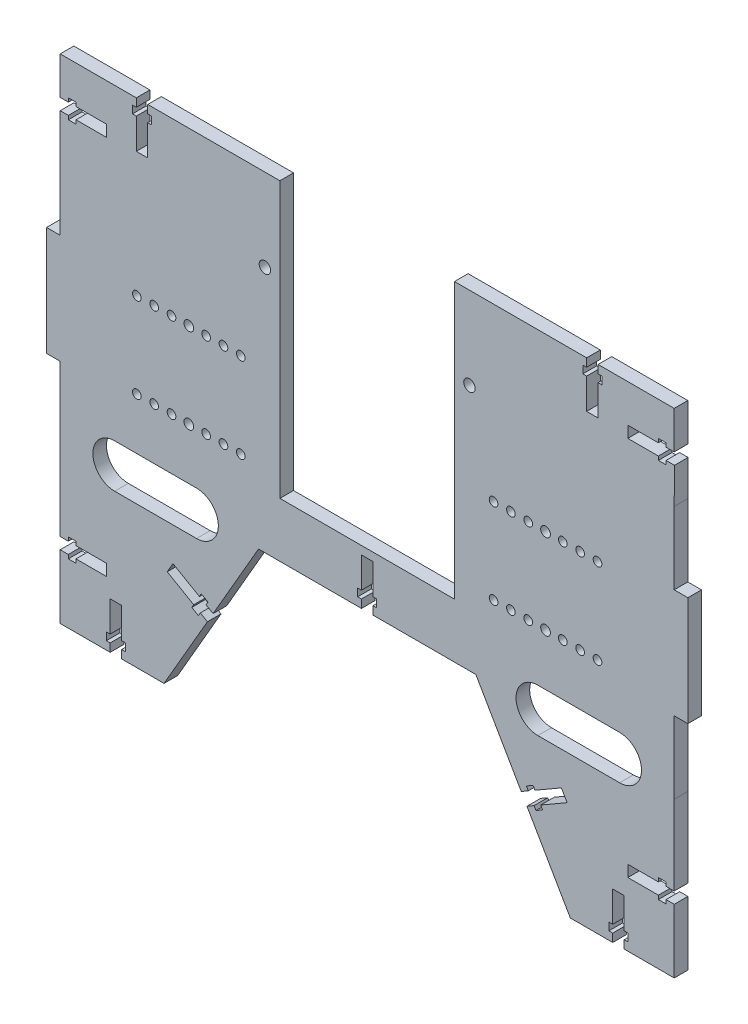
from build123d import *

# Parameters (mm, degrees)
SKETCH1_R           = 2.5
SKETCH1_R_2         = 2
SKETCH1_R_3         = 1.6
SKETCH1_W           = 33
SKETCH1_H           = 80
BOSS_EXTRUDE1_DEPTH = 5
SKETCH2_W           = 33
SKETCH2_H           = 80
BOSS_EXTRUDE2_DEPTH = 5
SKETCH3_W           = 23
SKETCH3_H           = 45
CUT_EXTRUDE3_DEPTH  = 5
SKETCH4_R           = 2.5
SKETCH4_R_2         = 2
SKETCH4_R_3         = 1.6
BOSS_EXTRUDE3_DEPTH = 5
SKETCH5_R           = 1.5875
SKETCH5_R_2         = 1.777507088
CUT_EXTRUDE4_DEPTH  = 5
CUT_EXTRUDE5_DEPTH  = 10
CUT_EXTRUDE9_DEPTH  = 10
CUT_EXTRUDE10_DEPTH = 10
SKETCH14_W          = 5
SKETCH14_H          = 4.2
CUT_EXTRUDE11_DEPTH = 10
SKETCH16_W          = 6.992402248
SKETCH16_H          = 3.319579164
CUT_EXTRUDE13_DEPTH = 5
SKETCH17_W          = 18
SKETCH17_H          = 45
CUT_EXTRUDE14_DEPTH = 5
SKETCH18_W          = 5
SKETCH18_H          = 100.853444487
BOSS_EXTRUDE4_DEPTH = 9
SKETCH19_R          = 2.1
CUT_EXTRUDE15_DEPTH = 5
BOSS_EXTRUDE5_DEPTH = 5
BOSS_EXTRUDE6_DEPTH = 5
CUT_EXTRUDE16_DEPTH = 5
CUT_EXTRUDE17_DEPTH = 5


with BuildPart() as part:
    # Sketch1 → Boss-Extrude1 (new body)
    with BuildSketch(Plane.XY):
        with BuildLine():
            Line((117.028043007, -95.833189988), (117.028043007, -34.826010178))
            Line((117.028043007, -34.826010178), (112.428043007, -34.826010178))
            ThreePointArc((112.428043007, -34.826010178), (108.892509101, -33.361544084), (107.428043007, -29.826010178))
            Line((107.428043007, -29.826010178), (107.428043007, 53.159630202))
            ThreePointArc((107.428043007, 53.159630202), (108.892509101, 56.695164108), (112.428043007, 58.159630202))
            Line((112.428043007, 58.159630202), (117.026703355, 58.159630202))
            Line((117.026703355, 58.159630202), (117.026347368, 74.955032384))
            Line((117.026347368, 74.955032384), (117.009335684, 95.020254499))
            Line((117.009335684, 95.020254499), (36.10896173, 95.020254499))
            ThreePointArc((36.10896173, 95.020254499), (-0.541956993, 85.455032384), (-37.192875715, 95.020254499))
            Line((-37.192875715, 95.020254499), (-118.09324967, 95.020254499))
            Line((-118.09324967, 95.020254499), (-118.110261354, 74.955032384))
            Line((-118.110261354, 74.955032384), (-118.110617341, 58.159630202))
            Line((-118.110617341, 58.159630202), (-113.511956993, 58.159630202))
            ThreePointArc((-113.511956993, 58.159630202), (-109.976423087, 56.695164108), (-108.511956993, 53.159630202))
            Line((-108.511956993, 53.159630202), (-108.511956993, -29.826010178))
            ThreePointArc((-108.511956993, -29.826010178), (-109.976423087, -33.361544084), (-113.511956993, -34.826010178))
            Line((-113.511956993, -34.826010178), (-118.111956993, -34.826010178))
            Line((-118.111956993, -34.826010178), (-118.111956993, -95.833189988))
            Line((-118.111956993, -95.833189988), (-72.133390372, -95.833189988))
            Line((-72.133390372, -95.833189988), (-37.492374221, -35.833189988))
            Line((-37.492374221, -35.833189988), (36.408460235, -35.833189988))
            Line((36.408460235, -35.833189988), (71.049476387, -95.833189988))
            Line((71.049476387, -95.833189988), (117.028043007, -95.833189988))
        make_face()
        with Locations((-93.741956993, 37.166810012)):
            Circle(SKETCH1_R, mode=Mode.SUBTRACT)
        with Locations((-93.741956993, -13.833189988)):
            Circle(SKETCH1_R, mode=Mode.SUBTRACT)
        with Locations((92.658043007, -13.833189988)):
            Circle(SKETCH1_R, mode=Mode.SUBTRACT)
        with Locations((92.658043007, 37.166810012)):
            Circle(SKETCH1_R, mode=Mode.SUBTRACT)
        with Locations((35.458043007, 29.166810012)):
            Circle(SKETCH1_R_2, mode=Mode.SUBTRACT)
        with Locations((35.458043007, -5.833189988)):
            Circle(SKETCH1_R_2, mode=Mode.SUBTRACT)
        with Locations((4.458043007, -5.833189988)):
            Circle(SKETCH1_R_2, mode=Mode.SUBTRACT)
        with Locations((-5.541956993, -5.833189988)):
            Circle(SKETCH1_R_2, mode=Mode.SUBTRACT)
        with Locations((-36.541956993, -5.833189988)):
            Circle(SKETCH1_R_2, mode=Mode.SUBTRACT)
        with Locations((-36.541956993, 29.166810012)):
            Circle(SKETCH1_R_2, mode=Mode.SUBTRACT)
        with Locations((4.458043007, 29.166810012)):
            Circle(SKETCH1_R_2, mode=Mode.SUBTRACT)
        with Locations((-5.541956993, 29.166810012)):
            Circle(SKETCH1_R_2, mode=Mode.SUBTRACT)
        with Locations((25.922509101, 60.990566289)):
            Circle(SKETCH1_R_3, mode=Mode.SUBTRACT)
        with Locations((25.922509101, 81.919498478)):
            Circle(SKETCH1_R_3, mode=Mode.SUBTRACT)
        with Locations((-27.006423087, 81.919498478)):
            Circle(SKETCH1_R_3, mode=Mode.SUBTRACT)
        with Locations((-27.006423087, 60.990566289)):
            Circle(SKETCH1_R_3, mode=Mode.SUBTRACT)
        with Locations((55.958043007, 11.666810012)):
            Rectangle(SKETCH1_W, SKETCH1_H, mode=Mode.SUBTRACT)
        with Locations((-57.041956993, 11.666810012)):
            Rectangle(SKETCH1_W, SKETCH1_H, mode=Mode.SUBTRACT)
    extrude(amount=BOSS_EXTRUDE1_DEPTH)

    # Sketch2 → Boss-Extrude2 (add)
    with BuildSketch(Plane.XY.offset(5)):
        with Locations((55.958043007, 11.666810012)):
            Rectangle(SKETCH2_W, SKETCH2_H)
        with Locations((-57.041956993, 11.666810012)):
            Rectangle(SKETCH2_W, SKETCH2_H)
    extrude(amount=-BOSS_EXTRUDE2_DEPTH)

    # Sketch3 → Cut-Extrude3 (cut)
    with BuildSketch(Plane.XY.offset(5)):
        with Locations((19.958043007, 10.9416372)):
            Rectangle(SKETCH3_W, SKETCH3_H)
        with Locations((-21.041956993, 10.9416372)):
            Rectangle(SKETCH3_W, SKETCH3_H)
    extrude(amount=-CUT_EXTRUDE3_DEPTH, mode=Mode.SUBTRACT)

    # Sketch4 → Boss-Extrude3 (add)
    with BuildSketch(Plane.XY.offset(5)):
        with Locations((92.658043007, -13.833189988)):
            Circle(SKETCH4_R)
        with Locations((92.658043007, 37.166810012)):
            Circle(SKETCH4_R)
        with Locations((35.458043007, -5.833189988)):
            Circle(SKETCH4_R_2)
        with Locations((35.458043007, 29.166810012)):
            Circle(SKETCH4_R_2)
        with Locations((4.458043007, -5.833189988)):
            Circle(SKETCH4_R_2)
        with Locations((4.458043007, 29.166810012)):
            Circle(SKETCH4_R_2)
        with Locations((-5.541956993, -5.833189988)):
            Circle(SKETCH4_R_2)
        with Locations((-5.541956993, 29.166810012)):
            Circle(SKETCH4_R_2)
        with Locations((-36.541956993, -5.833189988)):
            Circle(SKETCH4_R_2)
        with Locations((-36.541956993, 29.166810012)):
            Circle(SKETCH4_R_2)
        with Locations((-93.741956993, -13.833189988)):
            Circle(SKETCH4_R)
        with Locations((-93.741956993, 37.166810012)):
            Circle(SKETCH4_R)
        with Locations((25.922509101, 60.990566289)):
            Circle(SKETCH4_R_3)
        with Locations((25.922509101, 81.919498478)):
            Circle(SKETCH4_R_3)
        with Locations((-27.006423087, 81.919498478)):
            Circle(SKETCH4_R_3)
        with Locations((-27.006423087, 60.990566289)):
            Circle(SKETCH4_R_3)
    extrude(amount=-BOSS_EXTRUDE3_DEPTH)

    # Sketch5 → Cut-Extrude4 (cut)
    with BuildSketch(Plane.XY.offset(5)):
        with Locations((-84.979456993, 26.5626372)):
            Circle(SKETCH5_R)
        with Locations((-78.629456993, 26.5626372)):
            Circle(SKETCH5_R)
        with Locations((-72.279456993, 26.5626372)):
            Circle(SKETCH5_R)
        with Locations((-65.929456993, 26.5626372)):
            Circle(SKETCH5_R_2)
        with Locations((-59.579456993, 26.5626372)):
            Circle(SKETCH5_R)
        with Locations((-53.229456993, 26.5626372)):
            Circle(SKETCH5_R)
        with Locations((-46.879456993, 26.5626372)):
            Circle(SKETCH5_R)
        with Locations((-46.879456993, -4.682347762)):
            Circle(SKETCH5_R)
        with Locations((-53.229456993, -4.682347762)):
            Circle(SKETCH5_R)
        with Locations((-59.579456993, -4.682347762)):
            Circle(SKETCH5_R)
        with Locations((-65.929456993, -4.682347762)):
            Circle(SKETCH5_R_2)
        with Locations((-72.279456993, -4.682347762)):
            Circle(SKETCH5_R)
        with Locations((-78.629456993, -4.682347762)):
            Circle(SKETCH5_R)
        with Locations((-84.979456993, -4.682347762)):
            Circle(SKETCH5_R)
        with Locations((83.895543007, -4.682347762)):
            Circle(SKETCH5_R)
        with Locations((77.545543007, -4.682347762)):
            Circle(SKETCH5_R)
        with Locations((71.195543007, -4.682347762)):
            Circle(SKETCH5_R)
        with Locations((64.845543007, -4.682347762)):
            Circle(SKETCH5_R_2)
        with Locations((58.495543007, -4.682347762)):
            Circle(SKETCH5_R)
        with Locations((52.145543007, -4.682347762)):
            Circle(SKETCH5_R)
        with Locations((45.795543007, -4.682347762)):
            Circle(SKETCH5_R)
        with Locations((45.795543007, 26.5626372)):
            Circle(SKETCH5_R)
        with Locations((52.145543007, 26.5626372)):
            Circle(SKETCH5_R)
        with Locations((58.495543007, 26.5626372)):
            Circle(SKETCH5_R)
        with Locations((64.845543007, 26.5626372)):
            Circle(SKETCH5_R_2)
        with Locations((71.195543007, 26.5626372)):
            Circle(SKETCH5_R)
        with Locations((77.545543007, 26.5626372)):
            Circle(SKETCH5_R)
        with Locations((83.895543007, 26.5626372)):
            Circle(SKETCH5_R)
    extrude(amount=-CUT_EXTRUDE4_DEPTH, mode=Mode.SUBTRACT)

    # Sketch7 → Cut-Extrude5 (cut)
    with BuildSketch(Plane.XY.offset(5)):
        Polygon((-113.092855481, 89.295081687), (-113.092875715, 75.465081684), (-113.511956993, 58.159630202), (-118.110617341, 58.159630202), (-118.110261354, 74.955032384), (-118.09324967, 95.020254499), (-37.192875715, 95.020254499), (-37.192875715, 89.295081687), align=None)
        Polygon((36.10896173, 89.295081687), (112.008860559, 89.295081687), (112.00896173, 75.465081684), (117.026703355, 58.159630202), (117.026347368, 74.955032384), (117.009335684, 95.020254499), (36.10896173, 95.020254499), align=None)
        Polygon((112.028043007, -35.5483628), (112.028043007, -91.5583628), (73.936227733, -91.5583628), (73.236587254, -90.346549944), (58.037587254, -64.02110972), (39.295211581, -31.5583628), (-2.641539765, -31.5583628), (-37.491539765, -31.5583628), (-40.379125567, -31.5583628), (-59.12150124, -64.02110972), (-74.32050124, -90.346549944), (-75.020141718, -91.5583628), (-113.111956993, -91.5583628), (-113.111956993, -35.5483628), (-118.111956993, -34.826010178), (-118.111956993, -95.833189988), (-72.133390372, -95.833189988), (-37.492374221, -35.833189988), (36.408460235, -35.833189988), (71.049476387, -95.833189988), (117.028043007, -95.833189988), (117.028043007, -34.826010178), align=None)
    extrude(amount=-CUT_EXTRUDE5_DEPTH, mode=Mode.SUBTRACT)

    # Sketch9 → Cut-Extrude9 (cut)
    with BuildSketch(Plane.XY.offset(5)):
        with BuildLine():
            Line((-107.292875715, 69.865081684), (-107.292875715, 71.265081684))
            Line((-107.292875715, 71.265081684), (-96.092875715, 71.265081684))
            Line((-96.092875715, 71.265081684), (-96.092875715, 75.465081684))
            Line((-96.092875715, 75.465081684), (-107.292875715, 75.465081684))
            Line((-107.292875715, 75.465081684), (-107.292875715, 76.865081684))
            Line((-107.292875715, 76.865081684), (-110.092875715, 76.865081684))
            Line((-110.092875715, 76.865081684), (-110.092875715, 75.465081684))
            Line((-110.092875715, 75.465081684), (-113.092875715, 75.465081684))
            Line((-113.092875715, 75.465081684), (-113.143730828, 73.365081684))
            Line((-113.143730828, 73.365081684), (-113.511956993, 58.159630202))
            ThreePointArc((-113.511956993, 58.159630202), (-113.302231779, 58.155229799), (-113.092875715, 58.142036336))
            Line((-113.092875715, 58.142036336), (-113.092875715, 71.265081684))
            Line((-113.092875715, 71.265081684), (-110.092875715, 71.265081684))
            Line((-110.092875715, 71.265081684), (-110.092875715, 69.865081684))
            Line((-110.092875715, 69.865081684), (-107.292875715, 69.865081684))
        make_face()
        Polygon((-75.542875715, 89.295081687), (-79.742875715, 89.295081687), (-79.742875715, 86.295081684), (-81.142875715, 86.295081684), (-81.142875715, 83.495081684), (-79.742875715, 83.495081684), (-79.742875715, 72.295081687), (-75.542875715, 72.295081687), (-75.542875715, 83.495081684), (-74.142875715, 83.495081684), (-74.142875715, 86.295081684), (-75.542875715, 86.295081684), align=None)
        Polygon((-94.766956993, -91.5583628), (-90.566956993, -91.5583628), (-90.566956993, -88.558362803), (-89.166956993, -88.558362803), (-89.166956993, -85.758362803), (-90.566956993, -85.758362803), (-90.566956993, -74.5583628), (-94.766956993, -74.5583628), (-94.766956993, -85.758362803), (-96.166956993, -85.758362803), (-96.166956993, -88.558362803), (-94.766956993, -88.558362803), align=None)
        Polygon((-113.111956993, -63.9533628), (-113.111956993, -68.1533628), (-110.111956993, -68.1533628), (-110.111956993, -69.5533628), (-107.311956993, -69.5533628), (-107.311956993, -68.1533628), (-96.111956993, -68.1533628), (-96.111956993, -63.9533628), (-107.311956993, -63.9533628), (-107.311956993, -62.5533628), (-110.111956993, -62.5533628), (-110.111956993, -63.9533628), align=None)
        Polygon((-59.121501241, -64.021109722), (-57.021501241, -60.383803026), (-59.619577452, -58.883803026), (-58.919577452, -57.671367461), (-61.344448583, -56.271367461), (-62.044448583, -57.483803026), (-71.743933104, -51.883803027), (-73.843933104, -55.521109723), (-64.144448583, -61.121109722), (-64.844448583, -62.333545288), (-62.419577452, -63.733545288), (-61.719577452, -62.521109722), align=None)
        Polygon((78.659796186, 89.295081687), (74.459796186, 89.295081687), (74.459796186, 86.295081684), (73.059796186, 86.295081684), (73.059796186, 83.495081684), (74.459796186, 83.495081684), (74.459796186, 72.295081687), (78.659796186, 72.295081687), (78.659796186, 83.495081684), (80.059796186, 83.495081684), (80.059796186, 86.295081684), (78.659796186, 86.295081684), align=None)
        with BuildLine():
            Line((106.209796186, 75.465081684), (95.009796186, 75.465081684))
            Line((95.009796186, 75.465081684), (95.009796186, 71.265081684))
            Line((95.009796186, 71.265081684), (106.209796186, 71.265081684))
            Line((106.209796186, 71.265081684), (106.209796186, 69.865081684))
            Line((106.209796186, 69.865081684), (109.009796186, 69.865081684))
            Line((109.009796186, 69.865081684), (109.009796186, 71.265081684))
            Line((109.009796186, 71.265081684), (112.111506411, 71.265081684))
            Line((112.111506411, 71.265081684), (112.009796186, 58.142036336))
            ThreePointArc((112.009796186, 58.142036336), (112.218735389, 58.155212281), (112.428043007, 58.159630132))
            Line((112.428043007, 58.159630202), (117.026703355, 58.159630202))
            Line((117.026703355, 58.159630202), (112.00896173, 75.465081684))
            Line((112.00896173, 75.465081684), (109.009796186, 75.465081684))
            Line((109.009796186, 75.465081684), (109.009796186, 76.865081684))
            Line((109.009796186, 76.865081684), (106.209796186, 76.865081684))
            Line((106.209796186, 76.865081684), (106.209796186, 75.465081684))
        make_face()
        Polygon((58.536497923, -58.883803026), (55.938421712, -60.383803026), (58.038421712, -64.021109722), (60.636497923, -62.521109722), (61.336497923, -63.733545288), (63.761369054, -62.333545288), (63.061369054, -61.121109722), (72.760853575, -55.521109723), (70.660853575, -51.883803027), (60.961369054, -57.483803026), (60.261369054, -56.271367461), (57.836497923, -57.671367461), align=None)
        Polygon((89.483877463, -88.558362803), (89.483877463, -91.5583628), (93.683877463, -91.5583628), (93.683877463, -88.558362803), (95.083877463, -88.558362803), (95.083877463, -85.758362803), (93.683877463, -85.758362803), (93.683877463, -74.5583628), (89.483877463, -74.5583628), (89.483877463, -85.758362803), (88.083877463, -85.758362803), (88.083877463, -88.558362803), align=None)
        Polygon((109.028877463, -68.1533628), (112.028877463, -68.1533628), (112.028877463, -63.9533628), (109.028877463, -63.9533628), (109.028877463, -62.5533628), (106.228877463, -62.5533628), (106.228877463, -63.9533628), (95.028877463, -63.9533628), (95.028877463, -68.1533628), (106.228877463, -68.1533628), (106.228877463, -69.5533628), (109.028877463, -69.5533628), align=None)
    extrude(amount=-CUT_EXTRUDE9_DEPTH, mode=Mode.SUBTRACT)

    # Sketch13 → Cut-Extrude10 (cut)
    with BuildSketch(Plane.XY.offset(5)):
        Polygon((1.558460235, -31.5583628), (-2.641539765, -31.5583628), (-2.641539765, -28.5583628), (-4.041539765, -28.5583628), (-4.041539765, -25.7583628), (-2.641539765, -25.7583628), (-2.641539765, -14.5583628), (1.558460235, -14.5583628), (1.558460235, -25.7583628), (2.958460235, -25.7583628), (2.958460235, -28.5583628), (1.558460235, -28.5583628), align=None)
    extrude(amount=-CUT_EXTRUDE10_DEPTH, mode=Mode.SUBTRACT)

    # Sketch14 → Cut-Extrude11 (cut)
    with BuildSketch(Plane(origin=(15.806862585, 9.126096368, 0), x_dir=(0, 0, -1), z_dir=(0.866025404, 0.5, 0))):
        with Locations((-2.5, -82.363118254)):
            Rectangle(SKETCH14_W, SKETCH14_H)
    extrude(amount=-CUT_EXTRUDE11_DEPTH, mode=Mode.SUBTRACT)

    # Sketch16 → Cut-Extrude13 (cut)
    with BuildSketch(Plane.XY.offset(5)):
        with BuildLine():
            Line((-113.111956993, -35.5483628), (-113.111956993, -34.809984496))
            ThreePointArc((-113.111956993, -34.809984496), (-113.311796543, -34.822002151), (-113.511956993, -34.826010178))
            Line((-113.511956993, -34.826010178), (-118.111956993, -34.826010178))
            Line((-118.111956993, -34.826010178), (-113.111956993, -35.5483628))
        make_face()
        with Locations((115.524244131, -33.888573218)):
            Rectangle(SKETCH16_W, SKETCH16_H)
    extrude(amount=-CUT_EXTRUDE13_DEPTH, mode=Mode.SUBTRACT)

    # Sketch17 → Cut-Extrude14 (cut)
    with BuildSketch(Plane.XY.offset(5)):
        Polygon((-32.541956993, 89.295081687), (-45.802182127, 89.295081687), (-45.802182127, 123.249758014), (36.10896173, 123.249758014), (36.10896173, 89.295081687), (31.517618523, 89.295081687), (31.517618523, 33.4416372), (-32.541956993, 33.4416372), align=None)
        with Locations((-0.541956993, 10.9416372)):
            Rectangle(SKETCH17_W, SKETCH17_H)
    extrude(amount=-CUT_EXTRUDE14_DEPTH, mode=Mode.SUBTRACT)

    # Sketch18 → Boss-Extrude4 (add)
    with BuildSketch(Plane.ZY.offset(-31.458043007)):
        with Locations((2.5, 38.868359444)):
            Rectangle(SKETCH18_W, SKETCH18_H)
    extrude(amount=-BOSS_EXTRUDE4_DEPTH)

    # Sketch19 → Cut-Extrude15 (cut)
    with BuildSketch(Plane.XY.offset(5)):
        with Locations((36.958043007, 59.082581687)):
            Circle(SKETCH19_R)
        with Locations((-38.041956993, 59.082581687)):
            Circle(SKETCH19_R)
    extrude(amount=-CUT_EXTRUDE15_DEPTH, mode=Mode.SUBTRACT)

    # Sketch20 → Boss-Extrude5 (add)
    with BuildSketch(Plane.XY.offset(5)):
        Polygon((-74.142875715, 83.495081684), (-75.542875715, 83.495081684), (-75.542875715, 72.295081687), (-79.742875715, 72.295081687), (-79.742875715, 83.495081684), (-81.142875715, 83.495081684), (-81.142875715, 86.295081684), (-79.742875715, 86.295081684), (-79.742875715, 89.295081687), (-75.542875715, 89.295081687), (-75.542875715, 86.295081684), (-74.142875715, 86.295081684), align=None)
        Polygon((74.459796186, 89.295081687), (74.459796186, 86.295081684), (73.059796186, 86.295081684), (73.059796186, 83.495081684), (74.459796186, 83.495081684), (74.459796186, 72.295081687), (78.659796186, 72.295081687), (78.659796186, 83.495081684), (80.059796186, 83.495081684), (80.059796186, 86.295081684), (78.659796186, 86.295081684), (78.659796186, 89.295081687), align=None)
        with BuildLine():
            Line((-113.111956993, -34.809984496), (-113.092875715, 58.142036336))
            ThreePointArc((-113.092875715, 58.142036336), (-109.831236521, 56.543754432), (-108.511956993, 53.159630202))
            Line((-108.511956993, 53.159630202), (-108.511956993, -29.826010178))
            ThreePointArc((-108.511956993, -29.826010178), (-109.837722379, -33.21717517), (-113.111956993, -34.809984496))
        make_face()
        with BuildLine():
            Line((112.028043007, -34.809984496), (112.00979673, 58.142106499))
            ThreePointArc((112.00979673, 58.142106499), (108.747606118, 56.544062843), (107.428043007, 53.159630202))
            Line((107.428043007, 53.159630202), (107.428043007, -29.826010178))
            ThreePointArc((107.428043007, -29.826010178), (108.753808393, -33.21717517), (112.028043007, -34.809984496))
        make_face()
    extrude(amount=-BOSS_EXTRUDE5_DEPTH)

    # Sketch21 → Boss-Extrude6 (add)
    with BuildSketch(Plane.XY.offset(5)):
        Polygon((-118.098307256, 31.682974671), (-113.098307256, 31.682974671), (-113.106518493, -8.317025329), (-118.098307256, -8.317025329), align=None)
        Polygon((112.014393271, 31.682974671), (112.022604508, -8.317025329), (117.01439327, -8.317025329), (117.01439327, 31.682974671), align=None)
    extrude(amount=-BOSS_EXTRUDE6_DEPTH)

    # Sketch22 → Cut-Extrude16 (cut)
    with BuildSketch(Plane.XY.offset(5)):
        Polygon((79.909335684, 89.295081687), (84.109335684, 89.295081687), (84.109335684, 86.295081687), (85.509335684, 86.295081687), (85.509335684, 83.495081687), (84.109335684, 83.495081687), (84.109335684, 72.295081687), (79.909335684, 72.295081687), (79.909335684, 83.495081687), (78.509335684, 83.495081687), (78.509335684, 86.295081687), (79.909335684, 86.295081687), align=None)
        Polygon((-80.992415214, 89.295081687), (-80.992415214, 86.295081687), (-79.592415214, 86.295081687), (-79.592415214, 83.495081687), (-80.992415214, 83.495081687), (-80.992415214, 72.295081687), (-85.192415214, 72.295081687), (-85.192415214, 83.495081687), (-86.592415214, 83.495081687), (-86.592415214, 86.295081687), (-85.192415214, 86.295081687), (-85.192415214, 89.295081687), align=None)
    extrude(amount=-CUT_EXTRUDE16_DEPTH, mode=Mode.SUBTRACT)

    # Sketch23 → Cut-Extrude17 (cut)
    with BuildSketch(Plane.XY.offset(5)):
        with BuildLine():
            Line((-93.111956993, -23.5823628), (-63.111956993, -23.5823628))
            ThreePointArc((-63.111956993, -23.5823628), (-55.111956993, -31.5823628), (-63.111956993, -39.5823628))
            Line((-63.111956993, -39.5823628), (-93.111956993, -39.5823628))
            ThreePointArc((-93.111956993, -39.5823628), (-101.111956993, -31.5823628), (-93.111956993, -23.5823628))
        make_face()
        with BuildLine():
            Line((92.028877463, -23.5823628), (62.028877463, -23.5823628))
            ThreePointArc((62.028877463, -23.5823628), (54.028877463, -31.5823628), (62.028877463, -39.5823628))
            Line((62.028877463, -39.5823628), (92.028877463, -39.5823628))
            ThreePointArc((92.028877463, -39.5823628), (100.028877463, -31.5823628), (92.028877463, -23.5823628))
        make_face()
    extrude(amount=-CUT_EXTRUDE17_DEPTH, mode=Mode.SUBTRACT)


solid = part.part
